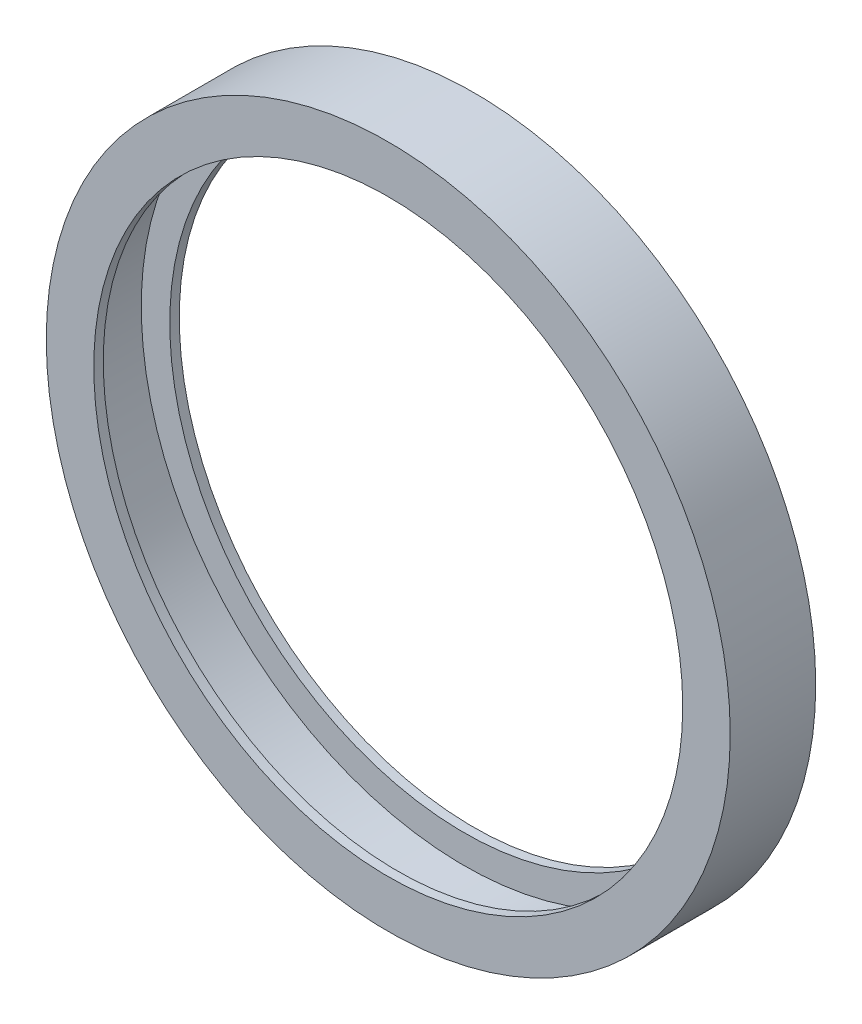
from build123d import *

# Parameters (mm, degrees)
SKETCH1_R           = 36
SKETCH1_R_2         = 31
BOSS_EXTRUDE1_DEPTH = 1
SKETCH2_R           = 36
SKETCH2_R_2         = 34
BOSS_EXTRUDE2_DEPTH = 7
SKETCH3_R           = 36
SKETCH3_R_2         = 31
BOSS_EXTRUDE3_DEPTH = 1


with BuildPart() as part:
    # Sketch1 → Boss-Extrude1 (new body)
    with BuildSketch(Plane.XY):
        Circle(SKETCH1_R)
        Circle(SKETCH1_R_2, mode=Mode.SUBTRACT)
    extrude(amount=BOSS_EXTRUDE1_DEPTH)

    # Sketch2 → Boss-Extrude2 (add)
    with BuildSketch(Plane.XY.offset(1)):
        Circle(SKETCH2_R)
        Circle(SKETCH2_R_2, mode=Mode.SUBTRACT)
    extrude(amount=BOSS_EXTRUDE2_DEPTH)

    # Sketch3 → Boss-Extrude3 (add)
    with BuildSketch(Plane.XY.offset(8)):
        Circle(SKETCH3_R)
        Circle(SKETCH3_R_2, mode=Mode.SUBTRACT)
    extrude(amount=BOSS_EXTRUDE3_DEPTH)


solid = part.part
